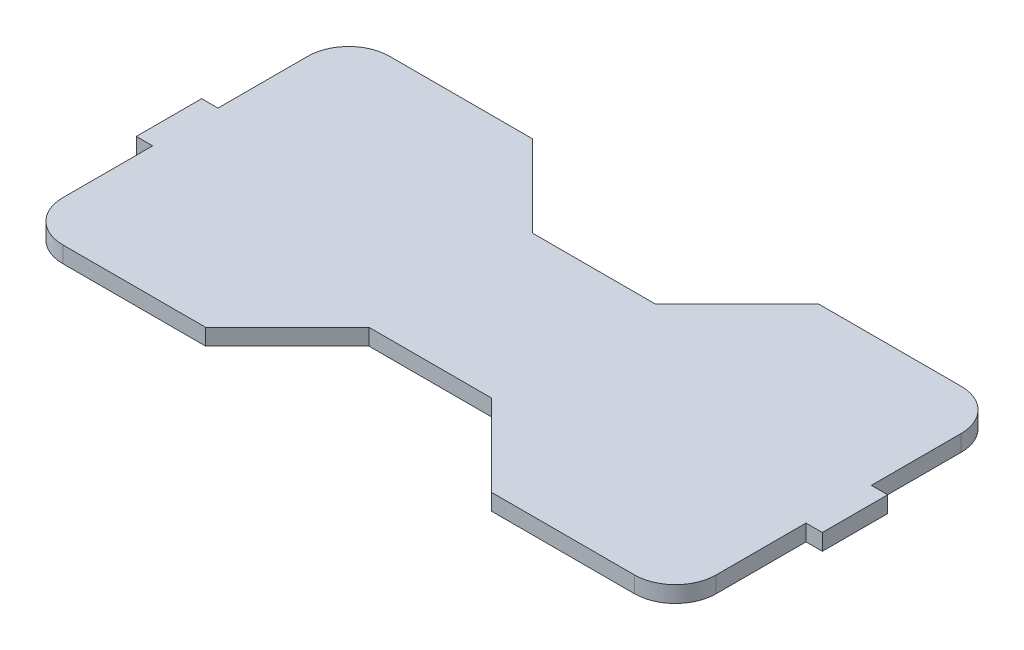
from build123d import *

# Parameters (mm, degrees)
BOSS_EXTRUDE1_DEPTH = 2.54
FILLET1_R           = 6.35


with BuildPart() as part:
    # Sketch1 → Boss-Extrude1 (new body)
    with BuildSketch(Plane(origin=(0, 0, 0), x_dir=(1, 0, 0), z_dir=(0, 1, 0))):
        Polygon((-9.525, 12.7), (-22.225, 25.4), (-50.8, 25.4), (-50.8, 5.08), (-53.34, 5.08), (-53.34, -5.08), (-50.8, -5.08), (-50.8, -25.4), (-22.225, -25.4), (-9.525, -12.7), (9.525, -12.7), (22.225, -25.4), (50.8, -25.4), (50.8, -5.08), (53.34, -5.08), (53.34, 5.08), (50.8, 5.08), (50.8, 25.4), (22.225, 25.4), (9.525, 12.7), align=None)
    extrude(amount=BOSS_EXTRUDE1_DEPTH)

    # Fillet1
    fillet1_edges = [part.edges().sort_by_distance(p)[0] for p in [
        (50.8, 1.27, -25.4),
        (50.8, 1.27, 25.4),
        (-50.8, 1.27, 25.4),
        (-50.8, 1.27, -25.4),
    ]]
    fillet(fillet1_edges, radius=FILLET1_R)


solid = part.part
